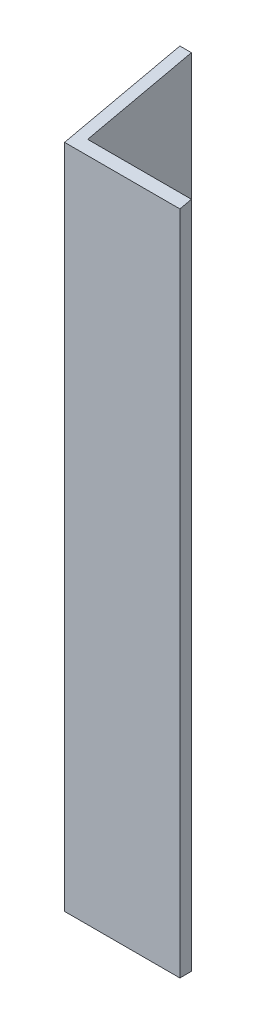
from build123d import *

# Parameters (mm, degrees)
SKETCH1_W           = 20
SKETCH1_H           = 120
BOSS_EXTRUDE1_DEPTH = 20
CUT_EXTRUDE2_DEPTH  = 20
SKETCH5_W           = 18
SKETCH5_H           = 18
CUT_EXTRUDE4_DEPTH  = 120


with BuildPart() as part:
    # Sketch1 → Boss-Extrude1 (new body)
    with BuildSketch(Plane.XY):
        with Locations((6.772727273, -55.795454545)):
            Rectangle(SKETCH1_W, SKETCH1_H)
    extrude(amount=-BOSS_EXTRUDE1_DEPTH)

    # Sketch4 → Cut-Extrude2 (cut)
    with BuildSketch(Plane.ZY.offset(3.227272727)):
        Polygon((-20, 4.204545455), (0, -0.265984203), (0, 4.204545455), align=None)
    extrude(amount=-CUT_EXTRUDE2_DEPTH, mode=Mode.SUBTRACT)

    # Sketch5 → Cut-Extrude4 (cut)
    with BuildSketch(Plane.XZ.offset(115.795454545)):
        with Locations((7.772727273, -11)):
            Rectangle(SKETCH5_W, SKETCH5_H)
    extrude(amount=-CUT_EXTRUDE4_DEPTH, mode=Mode.SUBTRACT)


solid = part.part
